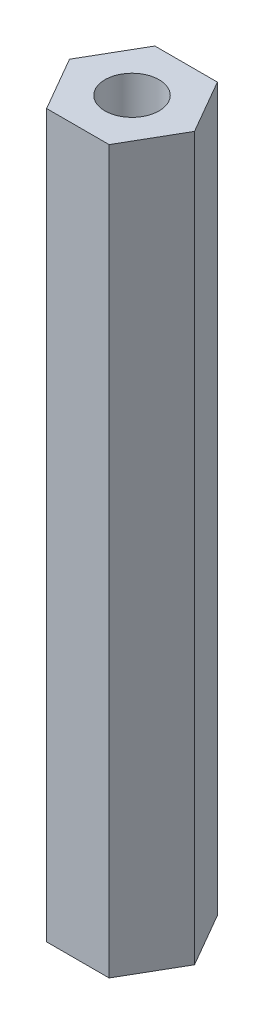
from build123d import *

# Parameters (mm, degrees)
SKETCH_1_R      = 1.5
EXTRUDE_1_DEPTH = 40


with BuildPart() as part:
    # 草圖1 → 填料-伸長1 (new body)
    with BuildSketch(Plane(origin=(0, 0, 0), x_dir=(1, 0, 0), z_dir=(0, 1, 0))):
        Polygon((3.464101615, 0), (1.732050808, 3), (-1.732050808, 3), (-3.464101615, 0), (-1.732050808, -3), (1.732050808, -3), align=None)
        Circle(SKETCH_1_R, mode=Mode.SUBTRACT)
    extrude(amount=EXTRUDE_1_DEPTH)


solid = part.part
